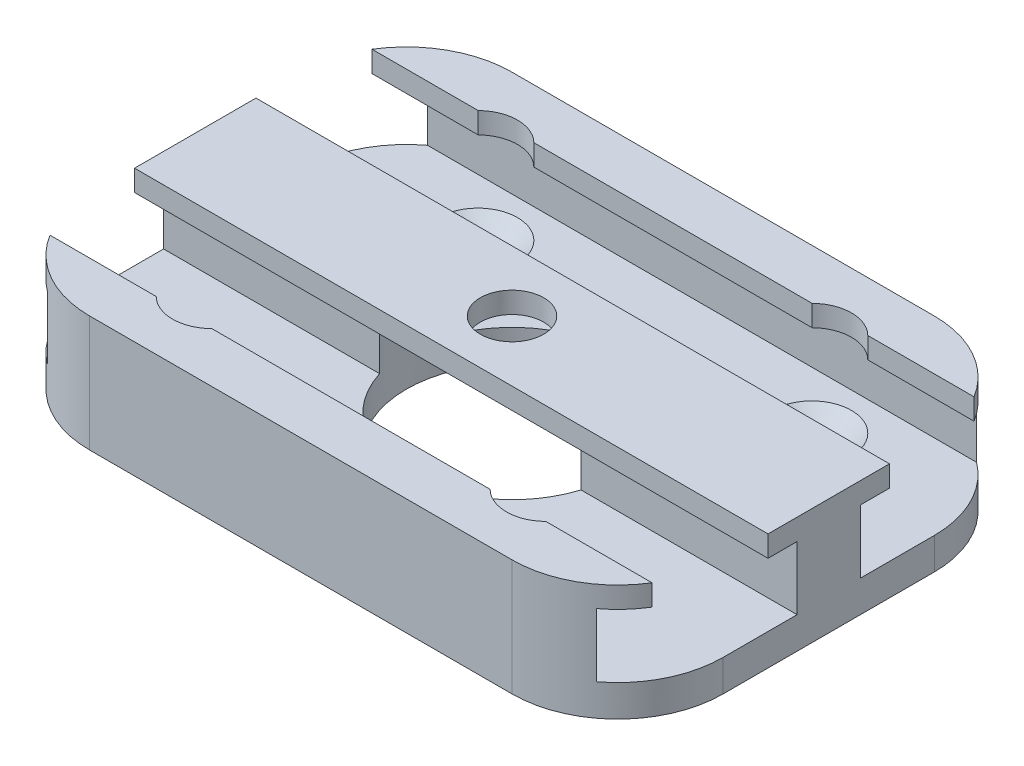
from build123d import *

# Parameters (mm, degrees)
SKETCH1_W                                    = 60
SKETCH1_H                                    = 40
BOSS_EXTRUDE1_DEPTH                          = 11
SKETCH3_W                                    = 15
SKETCH3_H                                    = 6
SKETCH3_W_2                                  = 9.5
SKETCH3_H_2                                  = 2
CUT_EXTRUDE10_DEPTH                          = 61
CSK_FOR_M3_HEX_SOCKET_COUNTERSUNK_CA_2_COUNT = 2
CSK_FOR_M3_HEX_SOCKET_COUNTERSUNK_CA_2_PITCH = 25.167603026
CSK_FOR_M3_HEX_SOCKET_COUNTERSUNK_CA_3_COUNT = 2
CSK_FOR_M3_HEX_SOCKET_COUNTERSUNK_CA_3_PITCH = 40.419124333
CSK_FOR_M3_HEX_SOCKET_COUNTERSUNK_CA_4_COUNT = 2
CSK_FOR_M3_HEX_SOCKET_COUNTERSUNK_CA_4_PITCH = 31.627478082
SKETCH1_6_R                                  = 10
CUT_EXTRUDE19_DEPTH                          = 9
CUT_EXTRUDE21_START                          = 11
SKETCH1_7_R                                  = 3
CUT_EXTRUDE21_DEPTH                          = 12
SKETCH8_R                                    = 3.75
CUT_EXTRUDE22_DEPTH                          = 2
FILLET1_R                                    = 10


with BuildPart() as part:
    # Sketch1 → Boss-Extrude1 (new body)
    with BuildSketch(Plane(origin=(0, 0, 0), x_dir=(1, 0, 0), z_dir=(0, 1, 0))):
        Rectangle(SKETCH1_W, SKETCH1_H)
    extrude(amount=BOSS_EXTRUDE1_DEPTH)

    # Sketch3 → Cut-Extrude10 (cut, through all)
    with BuildSketch(Plane.ZY.offset(30)):
        with Locations((10.5, 6)):
            Rectangle(SKETCH3_W, SKETCH3_H)
        with Locations((-10.5, 6)):
            Rectangle(SKETCH3_W, SKETCH3_H)
        with Locations((-10.5, 10)):
            Rectangle(SKETCH3_W_2, SKETCH3_H_2)
        with Locations((10.5, 10)):
            Rectangle(SKETCH3_W_2, SKETCH3_H_2)
    extrude(amount=-CUT_EXTRUDE10_DEPTH, mode=Mode.SUBTRACT)

    # Sketch7 → CSK for M3 Hex Socket Countersunk Cap Sc (revolve, cut)
    with BuildSketch(Plane(origin=(15.813739041, 3, -12.583801513), x_dir=(0, 0, 1), z_dir=(1, 0, 0))):
        Polygon((0, 0), (0, 3), (1.75, 3), (1.75, 2), (3.75, 0), align=None)
    csk_for_m3_hex_socket_countersunk_cap_sc = revolve(axis=Axis((15.813739041, 9.35, -12.583801513), (0, -1, 0)), mode=Mode.SUBTRACT)

    # CSK for M3 Hex Socket Countersunk Ca 2: CSK for M3 Hex Socket Countersunk Cap Sc ×2
    with Locations(*[(0, 0, i * CSK_FOR_M3_HEX_SOCKET_COUNTERSUNK_CA_2_PITCH) for i in range(1, CSK_FOR_M3_HEX_SOCKET_COUNTERSUNK_CA_2_COUNT)]):
        add(csk_for_m3_hex_socket_countersunk_cap_sc, mode=Mode.SUBTRACT)

    # CSK for M3 Hex Socket Countersunk Ca 3: CSK for M3 Hex Socket Countersunk Cap Sc ×2
    with Locations(*[Vector(-0.782487958, 0, 0.622665717) * (i * CSK_FOR_M3_HEX_SOCKET_COUNTERSUNK_CA_3_PITCH) for i in range(1, CSK_FOR_M3_HEX_SOCKET_COUNTERSUNK_CA_3_COUNT)]):
        add(csk_for_m3_hex_socket_countersunk_cap_sc, mode=Mode.SUBTRACT)

    # CSK for M3 Hex Socket Countersunk Ca 4: CSK for M3 Hex Socket Countersunk Cap Sc ×2
    with Locations(*[(-i * CSK_FOR_M3_HEX_SOCKET_COUNTERSUNK_CA_4_PITCH, 0, 0) for i in range(1, CSK_FOR_M3_HEX_SOCKET_COUNTERSUNK_CA_4_COUNT)]):
        add(csk_for_m3_hex_socket_countersunk_cap_sc, mode=Mode.SUBTRACT)

    # Sketch1_6 → Cut-Extrude19 (cut)
    with BuildSketch(Plane(origin=(0, 0, 0), x_dir=(1, 0, 0), z_dir=(0, 1, 0))):
        Circle(SKETCH1_6_R)
    extrude(amount=CUT_EXTRUDE19_DEPTH, mode=Mode.SUBTRACT)

    # Sketch1_7 → Cut-Extrude21 (cut, through all)
    with BuildSketch(Plane(origin=(0, 0, 0), x_dir=(1, 0, 0), z_dir=(0, 1, 0)).offset(CUT_EXTRUDE21_START)):
        Circle(SKETCH1_7_R)
    extrude(amount=-CUT_EXTRUDE21_DEPTH, mode=Mode.SUBTRACT)

    # Sketch8 → Cut-Extrude22 (cut)
    with BuildSketch(Plane(origin=(0, 11, 0), x_dir=(1, 0, 0), z_dir=(0, 1, 0))):
        with Locations((-15.813739041, -12.583801513)):
            Circle(SKETCH8_R)
        with Locations((15.813739041, -12.583801513)):
            Circle(SKETCH8_R)
        with Locations((15.813739041, 12.583801513)):
            Circle(SKETCH8_R)
        with Locations((-15.813739041, 12.583801513)):
            Circle(SKETCH8_R)
    extrude(amount=-CUT_EXTRUDE22_DEPTH, mode=Mode.SUBTRACT)

    # Fillet1
    fillet1_edges = [part.edges().sort_by_distance(p)[0] for p in [
        (30, 5.5, -20),
        (30, 5.5, 20),
        (-30, 5.5, 20),
        (-30, 5.5, -20),
    ]]
    fillet(fillet1_edges, radius=FILLET1_R)


solid = part.part
